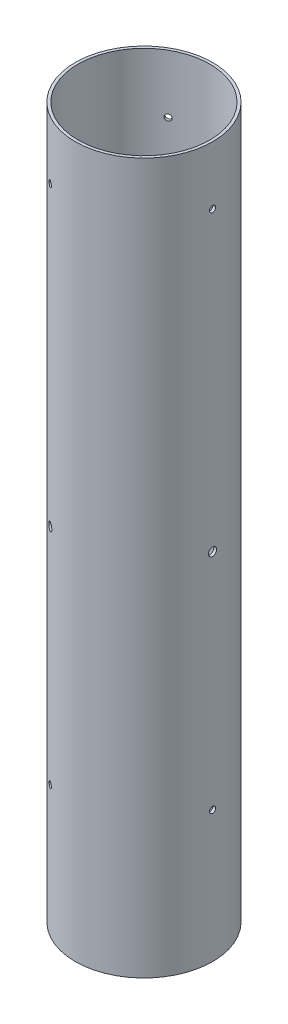
from build123d import *

# Parameters (mm, degrees)
SKETCH1_R                        = 39.7891
SKETCH1_R_2                      = 38.1635
BOSS_EXTRUDE1_DEPTH              = 411.48
CUT_EXTRUDE1_START               = -1.66704
SKETCH2_R                        = 1.778
CUT_EXTRUDE1_DEPTH               = 1.66704
CIRPATTERN1_COUNT                = 3
PRESSURE_START                   = -1.699963
SKETCH3_R                        = 2.38125
PRESSURE_EQUALIZATION_HOLE_DEPTH = 1.699963
CIRPATTERN2_COUNT                = 3
SKETCH4_R                        = 1.7859375
CUT_EXTRUDE3_DEPTH               = 1.667411
CIRPATTERN3_COUNT                = 3


with BuildPart() as part:
    # Sketch1 → Boss-Extrude1 (new body)
    with BuildSketch(Plane(origin=(0, 0, 0), x_dir=(1, 0, 0), z_dir=(0, 1, 0))):
        Circle(SKETCH1_R)
        Circle(SKETCH1_R_2, mode=Mode.SUBTRACT)
    extrude(amount=BOSS_EXTRUDE1_DEPTH)

    # Sketch2 → Cut-Extrude1 (cut)
    with BuildSketch(Plane(origin=(-19.89455, 0, 34.458371394), x_dir=(0, -1, 0), z_dir=(-0.5, 0, 0.866025404)).offset(CUT_EXTRUDE1_START)):
        with Locations((-76.2, 0)):
            Circle(SKETCH2_R)
    cut_extrude1 = extrude(amount=CUT_EXTRUDE1_DEPTH, mode=Mode.SUBTRACT)

    # CirPattern1: Cut-Extrude1 ×3 about axis
    cirpattern1_axis = Axis((0, -7.62, 0), (0, 1, 0))
    for i in range(1, CIRPATTERN1_COUNT):
        add(cut_extrude1.rotate(cirpattern1_axis, i * 360 / CIRPATTERN1_COUNT), mode=Mode.SUBTRACT)

    # Sketch3 → Pressure Equalization Hole (cut)
    with BuildSketch(Plane(origin=(-19.89455, 0, 34.458371394), x_dir=(0, -1, 0), z_dir=(-0.5, 0, 0.866025404)).offset(PRESSURE_START)):
        with Locations((-205.74, 0)):
            Circle(SKETCH3_R)
    pressure_equalization_hole = extrude(amount=PRESSURE_EQUALIZATION_HOLE_DEPTH, mode=Mode.SUBTRACT)

    # CirPattern2: Pressure Equalization Hole ×3 about axis
    cirpattern2_axis = Axis((0, -7.62, 0), (0, 1, 0))
    for i in range(1, CIRPATTERN2_COUNT):
        add(pressure_equalization_hole.rotate(cirpattern2_axis, i * 360 / CIRPATTERN2_COUNT), mode=Mode.SUBTRACT)

    # Sketch4 → Cut-Extrude3 (cut)
    with BuildSketch(Plane(origin=(39.7891, 0, 0), x_dir=(0, -1, 0), z_dir=(-1, 0, 0))):
        with Locations((-377.6726, 0)):
            Circle(SKETCH4_R)
    cut_extrude3 = extrude(amount=CUT_EXTRUDE3_DEPTH, mode=Mode.SUBTRACT)

    # CirPattern3: Cut-Extrude3 ×3 about axis
    cirpattern3_axis = Axis((0, -7.62, 0), (0, 1, 0))
    for i in range(1, CIRPATTERN3_COUNT):
        add(cut_extrude3.rotate(cirpattern3_axis, i * 360 / CIRPATTERN3_COUNT), mode=Mode.SUBTRACT)


solid = part.part
